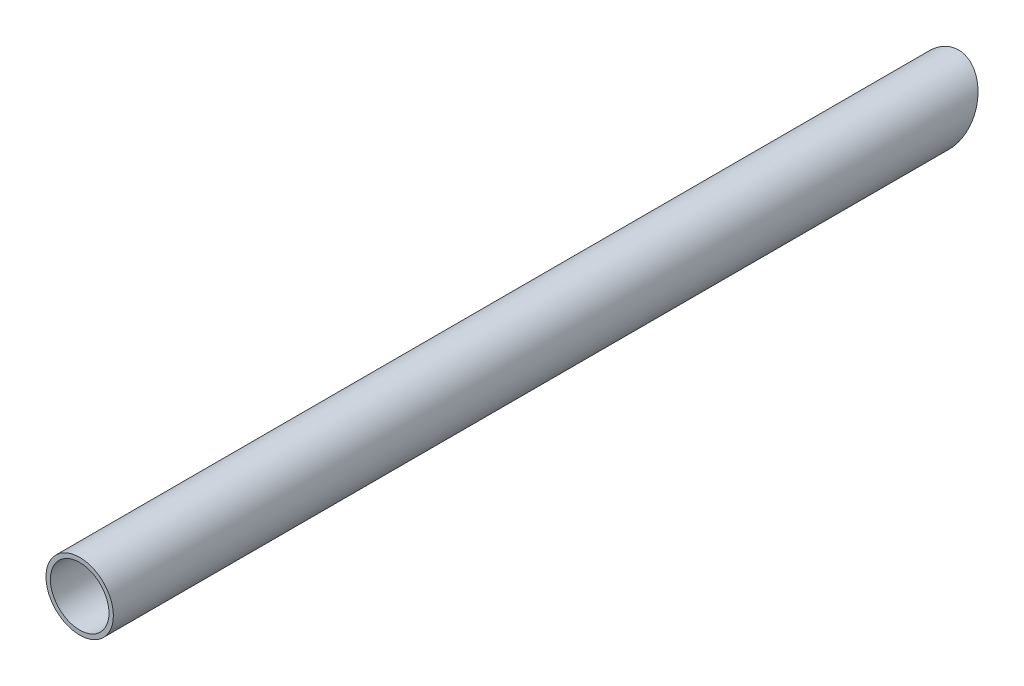
from build123d import *

# Parameters (mm, degrees)
SKETCH1_R           = 11.5
SKETCH1_R_2         = 10
BOSS_EXTRUDE1_DEPTH = 150
CUT_EXTRUDE1_DEPTH  = 150


with BuildPart() as part:
    # Sketch1 → Boss-Extrude1 (new, symmetric)
    with BuildSketch(Plane.XY):
        Circle(SKETCH1_R)
        Circle(SKETCH1_R_2, mode=Mode.SUBTRACT)
    extrude(amount=BOSS_EXTRUDE1_DEPTH, both=True)

    # Sketch2 → Cut-Extrude1 (cut, symmetric)
    with BuildSketch(Plane(origin=(0, 0, 0), x_dir=(0, 0, -1), z_dir=(1, 0, 0))):
        Polygon((150, 11.5), (136.720943809, -11.5), (150, -11.5), align=None)
    extrude(amount=CUT_EXTRUDE1_DEPTH, both=True, mode=Mode.SUBTRACT)


solid = part.part
